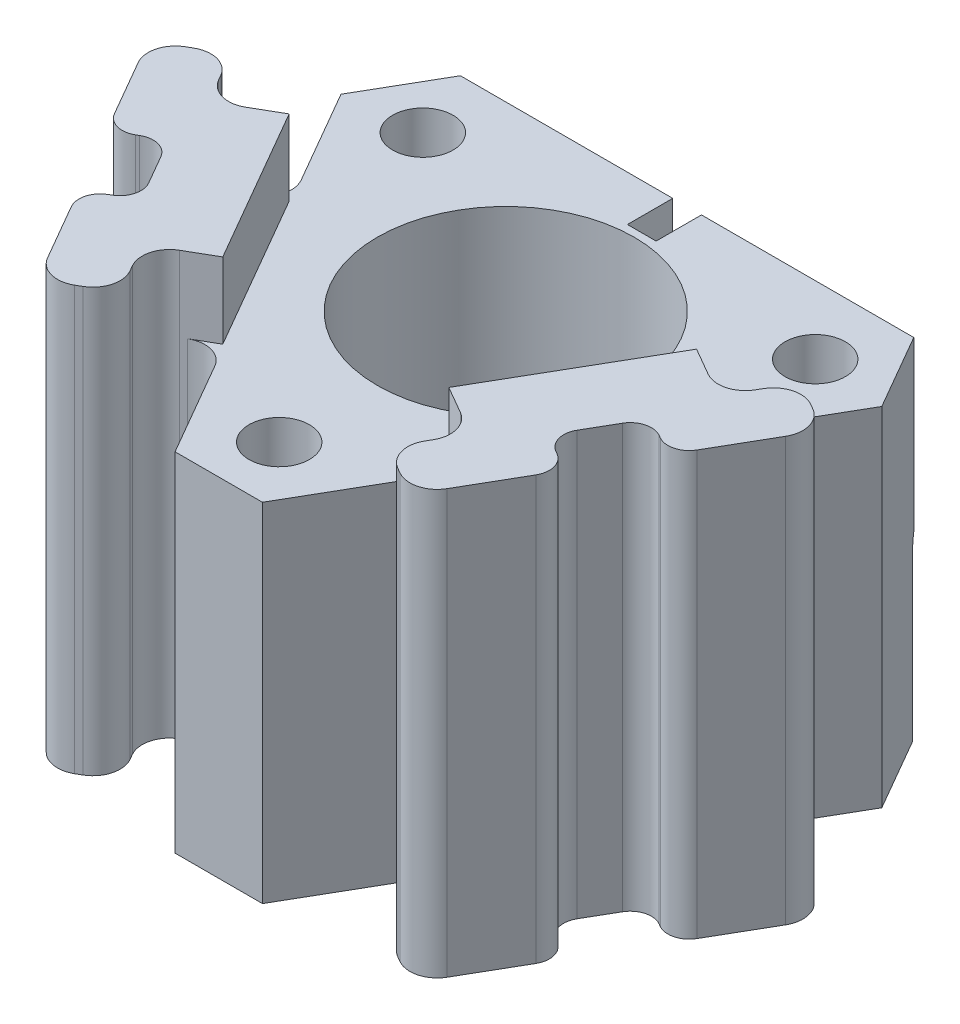
from build123d import *

# Parameters (mm, degrees)
ESQUISSE2_R                  = 8.5
BOSS_EXTRU_1_DEPTH           = 23
ENL_V_START                  = 23
ESQUISSE3_R                  = 2
ENL_V_MAT_EXTRU_3_DEPTH      = 24
ENL_V_MAT_EXTRU_3_DEPTH_BACK = 8
ENL_V_START_2                = -12
ESQUISSE4_R                  = 1.5
ENL_V_MAT_EXTRU_4_DEPTH      = 8
BOSS_EXTRU_2_DEPTH           = 28
CONG_5_R                     = 1.8
ENL_V_MAT_EXTRU_5_DEPTH      = 5
ESQUISSE7_R                  = 1.5
ESQUISSE7_W                  = 1.9
ESQUISSE7_H                  = 0.1
ENL_V_MAT_EXTRU_6_DEPTH      = 3
CONG_6_R                     = 3


with BuildPart() as part:
    # Esquisse2 → Boss.-Extru.1 (new body)
    with BuildSketch(Plane(origin=(0, 0, 0), x_dir=(1, 0, 0), z_dir=(0, 1, 0))):
        Polygon((15, 12), (-15, 12), (-17.892304845, 6.990381057), (-2.892304845, -18.990381057), (2.892304845, -18.990381057), (17.892304845, 6.990381057), align=None)
        Circle(ESQUISSE2_R, mode=Mode.SUBTRACT)
    extrude(amount=BOSS_EXTRU_1_DEPTH)

    # Esquisse3 → Enl_v. mat.-Extru.3 (cut, two sides)
    with BuildSketch(Plane(origin=(0, 0, 0), x_dir=(1, 0, 0), z_dir=(0, 1, 0)).offset(ENL_V_START)) as enl_v_mat_extru_3_sk:
        with Locations((-12.982050808, 7.495190528)):
            Circle(ESQUISSE3_R)
        with Locations((12.982050808, 7.495190528)):
            Circle(ESQUISSE3_R)
        with Locations((0, -14.990381057)):
            Circle(ESQUISSE3_R)
    extrude(amount=ENL_V_MAT_EXTRU_3_DEPTH, mode=Mode.SUBTRACT)
    extrude(enl_v_mat_extru_3_sk.sketch, amount=-ENL_V_MAT_EXTRU_3_DEPTH_BACK, mode=Mode.SUBTRACT)

    # Esquisse4 → Enl_v. mat.-Extru.4 (cut)
    with BuildSketch(Plane.XY.offset(ENL_V_START_2)):
        with Locations((-11, 11)):
            Circle(ESQUISSE4_R)
        with Locations((11, 11)):
            Circle(ESQUISSE4_R)
        with Locations((11, 3)):
            Circle(ESQUISSE4_R)
        with Locations((-11, 3)):
            Circle(ESQUISSE4_R)
    extrude(amount=ENL_V_MAT_EXTRU_4_DEPTH, mode=Mode.SUBTRACT)

    # Esquisse5 → Boss.-Extru.2 (add)
    with BuildSketch(Plane(origin=(0, 0, 0), x_dir=(1, 0, 0), z_dir=(0, 1, 0))):
        with BuildLine():
            Line((13.220508076, -17.101408311), (15.370508076, -13.377499075))
            ThreePointArc((15.370508076, -13.377499075), (15.510368667, -12.315152412), (14.85807251, -11.465063509))
            Line((14.85807251, -11.465063509), (14.68486743, -11.365063509))
            ThreePointArc((14.68486743, -11.365063509), (14.032571273, -10.514974607), (14.172431864, -9.452627944))
            Line((14.172431864, -9.452627944), (15.272431864, -7.547372056))
            ThreePointArc((15.272431864, -7.547372056), (16.122520766, -6.895075899), (17.18486743, -7.034936491))
            Line((17.18486743, -7.034936491), (17.35807251, -7.134936491))
            ThreePointArc((17.35807251, -7.134936491), (18.420419174, -7.274797082), (19.270508076, -6.622500925))
            Line((19.270508076, -6.622500925), (21.420508076, -2.898591689))
            ThreePointArc((21.420508076, -2.898591689), (21.600328836, -1.532717408), (20.761662349, -0.439745962))
            Line((20.761662349, -0.439745962), (20.415252187, -0.239745962))
            ThreePointArc((20.415252187, -0.239745962), (19.049377906, -0.059925202), (17.956406461, -0.898591689))
            Line((17.956406461, -0.898591689), (17.756406461, -1.24500185))
            ThreePointArc((17.756406461, -1.24500185), (16.663435015, -2.083668338), (15.297560734, -1.903847577))
            Line((15.297560734, -1.903847577), (13.392304845, -0.803847577))
            Line((13.392304845, -0.803847577), (7.392304845, -11.196152423))
            Line((7.392304845, -11.196152423), (9.297560734, -12.296152423))
            ThreePointArc((9.297560734, -12.296152423), (10.136227221, -13.389123868), (9.956406461, -14.75499815))
            Line((9.956406461, -14.75499815), (9.756406461, -15.101408311))
            ThreePointArc((9.756406461, -15.101408311), (9.5765857, -16.467282592), (10.415252187, -17.560254038))
            Line((10.415252187, -17.560254038), (10.761662349, -17.760254038))
            ThreePointArc((10.761662349, -17.760254038), (12.12753663, -17.940074798), (13.220508076, -17.101408311))
        make_face()
        with BuildLine():
            Line((-19.270508076, -6.622500925), (-21.420508076, -2.898591689))
            ThreePointArc((-21.420508076, -2.898591689), (-21.600328836, -1.532717408), (-20.761662349, -0.439745962))
            Line((-20.761662349, -0.439745962), (-20.415252187, -0.239745962))
            ThreePointArc((-20.415252187, -0.239745962), (-19.049377906, -0.059925202), (-17.956406461, -0.898591689))
            Line((-17.956406461, -0.898591689), (-17.756406461, -1.24500185))
            ThreePointArc((-17.756406461, -1.24500185), (-16.663435015, -2.083668338), (-15.297560734, -1.903847577))
            Line((-15.297560734, -1.903847577), (-13.392304845, -0.803847577))
            Line((-13.392304845, -0.803847577), (-7.392304845, -11.196152423))
            Line((-7.392304845, -11.196152423), (-9.297560734, -12.296152423))
            ThreePointArc((-9.297560734, -12.296152423), (-10.136227221, -13.389123868), (-9.956406461, -14.75499815))
            Line((-9.956406461, -14.75499815), (-9.756406461, -15.101408311))
            ThreePointArc((-9.756406461, -15.101408311), (-9.5765857, -16.467282592), (-10.415252187, -17.560254038))
            Line((-10.415252187, -17.560254038), (-10.761662349, -17.760254038))
            ThreePointArc((-10.761662349, -17.760254038), (-12.12753663, -17.940074798), (-13.220508076, -17.101408311))
            Line((-13.220508076, -17.101408311), (-15.370508076, -13.377499075))
            ThreePointArc((-15.370508076, -13.377499075), (-15.510368667, -12.315152412), (-14.85807251, -11.465063509))
            Line((-14.85807251, -11.465063509), (-14.68486743, -11.365063509))
            ThreePointArc((-14.68486743, -11.365063509), (-14.032571273, -10.514974607), (-14.172431864, -9.452627944))
            Line((-14.172431864, -9.452627944), (-15.272431864, -7.547372056))
            ThreePointArc((-15.272431864, -7.547372056), (-16.122520766, -6.895075899), (-17.18486743, -7.034936491))
            Line((-17.18486743, -7.034936491), (-17.35807251, -7.134936491))
            ThreePointArc((-17.35807251, -7.134936491), (-18.420419174, -7.274797082), (-19.270508076, -6.622500925))
        make_face()
    extrude(amount=BOSS_EXTRU_2_DEPTH)

    # Cong_5
    cong_5_edges = [part.edges().sort_by_distance(p)[0] for p in [
        (-7.392304845, 11.5, 11.196152423),
        (7.392304845, 11.5, 11.196152423),
        (13.392304845, 11.5, 0.803847577),
        (-13.392304845, 11.5, 0.803847577),
    ]]
    fillet(cong_5_edges, radius=CONG_5_R)

    # Esquisse6 → Enl_v. mat.-Extru.5 (cut)
    with BuildSketch(Plane(origin=(0, 0, 0), x_dir=(1, 0, 0), z_dir=(0, 1, 0)).offset(ENL_V_START)):
        Polygon((-13.392304845, -0.803847577), (-7.392304845, -11.196152423), (-7.478907386, -11.246152423), (-13.478907386, -0.853847577), align=None)
        Polygon((7.392304845, -11.196152423), (13.392304845, -0.803847577), (13.478907386, -0.853847577), (7.478907386, -11.246152423), align=None)
    extrude(amount=ENL_V_MAT_EXTRU_5_DEPTH, mode=Mode.SUBTRACT)

    # Esquisse7 → Enl_v. mat.-Extru.6 (cut)
    with BuildSketch(Plane(origin=(0, 0, -12), x_dir=(-1, 0, 0), z_dir=(0, 0, -1))):
        Polygon((15, 0), (0.85, 0), (-0.85, 0), (-15, 0), (-15, 14.1), (-15.1, 14.1), (-15.1, -0.1), (15.1, -0.1), (15.1, 14.1), (15, 14.1), align=None)
        Polygon((-0.85, 0), (0.85, 0), (15, 0), (15, 14.1), (0.95, 14.1), (0.95, 23), (-0.95, 23), (-0.95, 14.1), (-15, 14.1), (-15, 0), align=None)
        with Locations((-11, 3)):
            Circle(ESQUISSE7_R, mode=Mode.SUBTRACT)
        with Locations((-11, 11)):
            Circle(ESQUISSE7_R, mode=Mode.SUBTRACT)
        with Locations((11, 3)):
            Circle(ESQUISSE7_R, mode=Mode.SUBTRACT)
        with Locations((11, 11)):
            Circle(ESQUISSE7_R, mode=Mode.SUBTRACT)
        with Locations((0, 23.05)):
            Rectangle(ESQUISSE7_W, ESQUISSE7_H)
    extrude(amount=-ENL_V_MAT_EXTRU_6_DEPTH, mode=Mode.SUBTRACT)

    # Cong_6
    cong_6_edges = [part.edges().sort_by_distance(p)[0] for p in [
        (-15.1, 14.1, -10.41339746),
        (15.1, 14.1, -10.41339746),
    ]]
    fillet(cong_6_edges, radius=CONG_6_R)


solid = part.part
